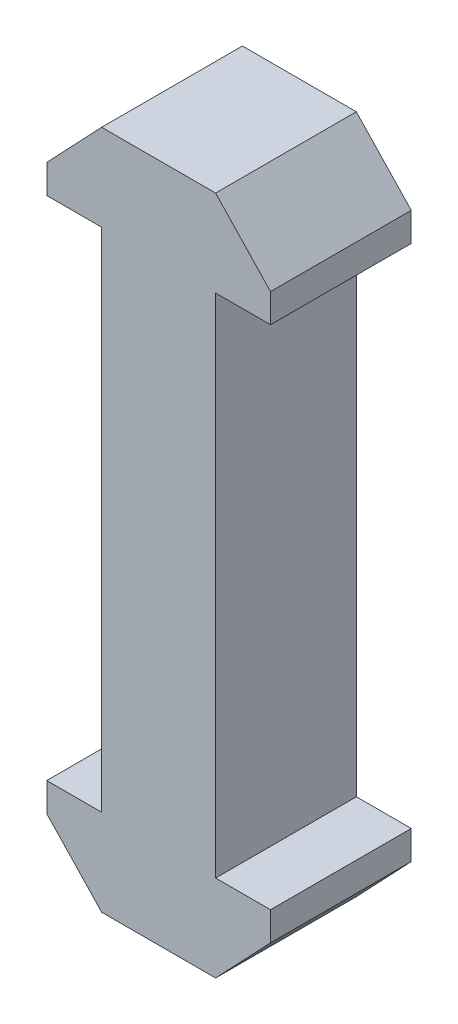
from build123d import *

# Parameters (mm, degrees)
BOSS_EXTRUDE1_DEPTH = 5


with BuildPart() as part:
    # Sketch1 → Boss-Extrude1 (new body, symmetric)
    with BuildSketch(Plane.XY):
        Polygon((7.95, 0), (4.05, 0), (4.05, 36), (7.95, 36), (7.95, 38.04), (4.048, 42.152414984), (-4.048, 42.152414984), (-7.95, 38.04), (-7.95, 36), (-4.05, 36), (-4.05, 0), (-7.95, 0), (-7.95, -2.04), (-4.048, -6.152414984), (4.048, -6.152414984), (7.95, -2.04), align=None)
    extrude(amount=BOSS_EXTRUDE1_DEPTH, both=True)


solid = part.part
